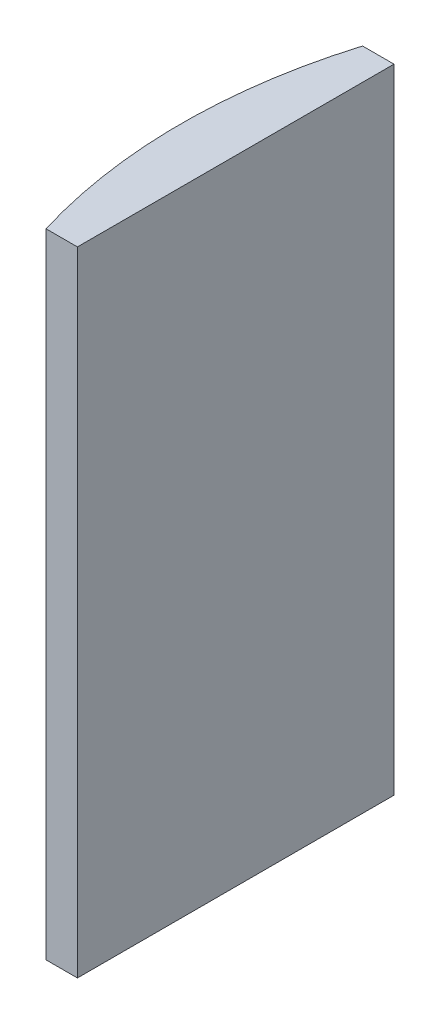
from build123d import *

# Parameters (mm, degrees)
EXTRUDE_1_DEPTH = 60


with BuildPart() as part:
    # 草图1 → 凸台-拉伸1 (new body)
    with BuildSketch(Plane(origin=(0, 0, 0), x_dir=(1, 0, 0), z_dir=(0, 1, 0))):
        with BuildLine():
            Line((-45.120951538, 15), (-42.144795665, 15))
            Line((-42.144795665, 15), (-42.144795665, -15))
            Line((-42.144795665, -15), (-45.120951538, -15))
            ThreePointArc((-45.120951538, -15), (-47.344795665, 0), (-45.120951538, 15))
        make_face()
    extrude(amount=EXTRUDE_1_DEPTH)


solid = part.part
